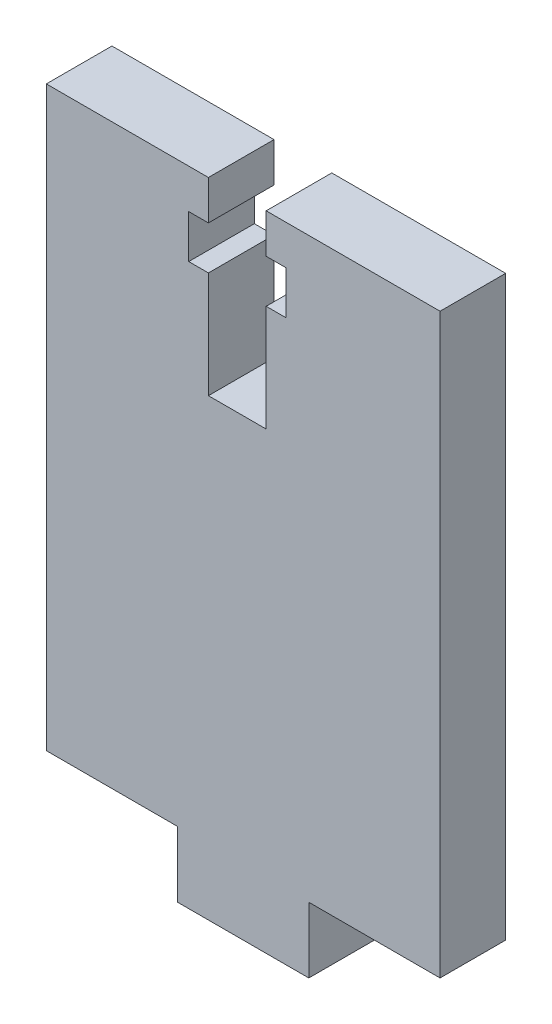
from build123d import *

# Parameters (mm, degrees)
BOSS_EXTRUDE1_DEPTH = 5
CUT_EXTRUDE1_DEPTH  = 5


with BuildPart() as part:
    # Sketch1 → Boss-Extrude1 (new body)
    with BuildSketch(Plane.XY):
        Polygon((-5.27676951, 0), (4.72323049, 0), (4.72323049, 5), (14.72323049, 5), (14.72323049, 49), (-15.27676951, 49), (-15.27676951, 5), (-5.27676951, 5), align=None)
    extrude(amount=BOSS_EXTRUDE1_DEPTH)

    # Sketch2 → Cut-Extrude1 (cut)
    with BuildSketch(Plane(origin=(0, 0, 0), x_dir=(-1, 0, 0), z_dir=(0, 0, -1))):
        Polygon((-1.472855596, 34.6), (2.927144404, 34.6), (2.927144404, 42.7), (4.427144404, 42.7), (4.427144404, 46), (2.927144404, 46), (2.927144404, 49), (-1.472855596, 49), (-1.472855596, 46), (-2.972855596, 46), (-2.972855596, 42.7), (-1.472855596, 42.7), align=None)
    extrude(amount=-CUT_EXTRUDE1_DEPTH, mode=Mode.SUBTRACT)


solid = part.part
